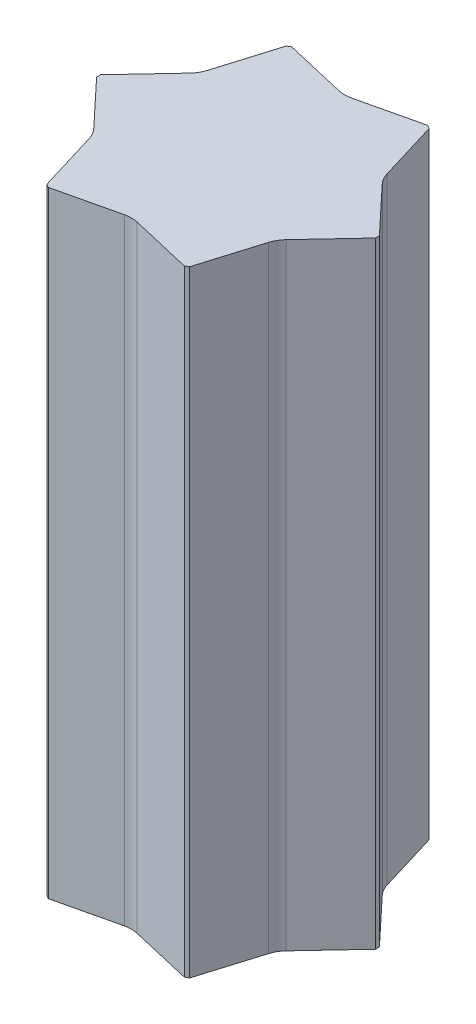
from build123d import *

# Parameters (mm, degrees)
EXTRUDE_1_DEPTH = 1480


with BuildPart() as part:
    # 草图7 → 凸台-拉伸1 (new body)
    with BuildSketch(Plane(origin=(0, 0, 0), x_dir=(1, 0, 0), z_dir=(0, 1, 0))):
        with BuildLine():
            Line((-163.425407286, 292.470977468), (-171.574592714, 287.766043068))
            Line((-171.574592714, 287.766043068), (-215.64921864, 142.144339856))
            ThreePointArc((-215.64921864, 142.144339856), (-221.758129252, 128.033988921), (-230.922998757, 115.687898132))
            Line((-230.922998757, 115.687898132), (-335, 4.7049344))
            Line((-335, 4.7049344), (-335, -4.7049344))
            Line((-335, -4.7049344), (-230.92521864, -115.68553172))
            ThreePointArc((-230.92521864, -115.68553172), (-221.75975158, -128.031178968), (-215.650158071, -142.141234176))
            Line((-215.650158071, -142.141234176), (-171.574592714, -287.766043068))
            Line((-171.574592714, -287.766043068), (-163.425407286, -292.470977468))
            Line((-163.425407286, -292.470977468), (-15.276, -257.829871576))
            ThreePointArc((-15.276, -257.829871576), (-0.001622327, -256.065167889), (15.272840686, -257.829132308))
            Line((15.272840686, -257.829132308), (163.425407286, -292.470977468))
            Line((163.425407286, -292.470977468), (171.574592714, -287.766043068))
            Line((171.574592714, -287.766043068), (215.64921864, -142.144339856))
            ThreePointArc((215.64921864, -142.144339856), (221.758129252, -128.033988921), (230.922998757, -115.687898132))
            Line((230.922998757, -115.687898132), (335, -4.7049344))
            Line((335, -4.7049344), (335, 4.7049344))
            Line((335, 4.7049344), (230.92521864, 115.68553172))
            ThreePointArc((230.92521864, 115.68553172), (221.75975158, 128.031178968), (215.650158071, 142.141234176))
            Line((215.650158071, 142.141234176), (171.574592714, 287.766043068))
            Line((171.574592714, 287.766043068), (163.425407286, 292.470977468))
            Line((163.425407286, 292.470977468), (15.276, 257.829871576))
            ThreePointArc((15.276, 257.829871576), (0.001622327, 256.065167889), (-15.272840686, 257.829132308))
            Line((-15.272840686, 257.829132308), (-163.425407286, 292.470977468))
        make_face()
    extrude(amount=EXTRUDE_1_DEPTH)


solid = part.part
